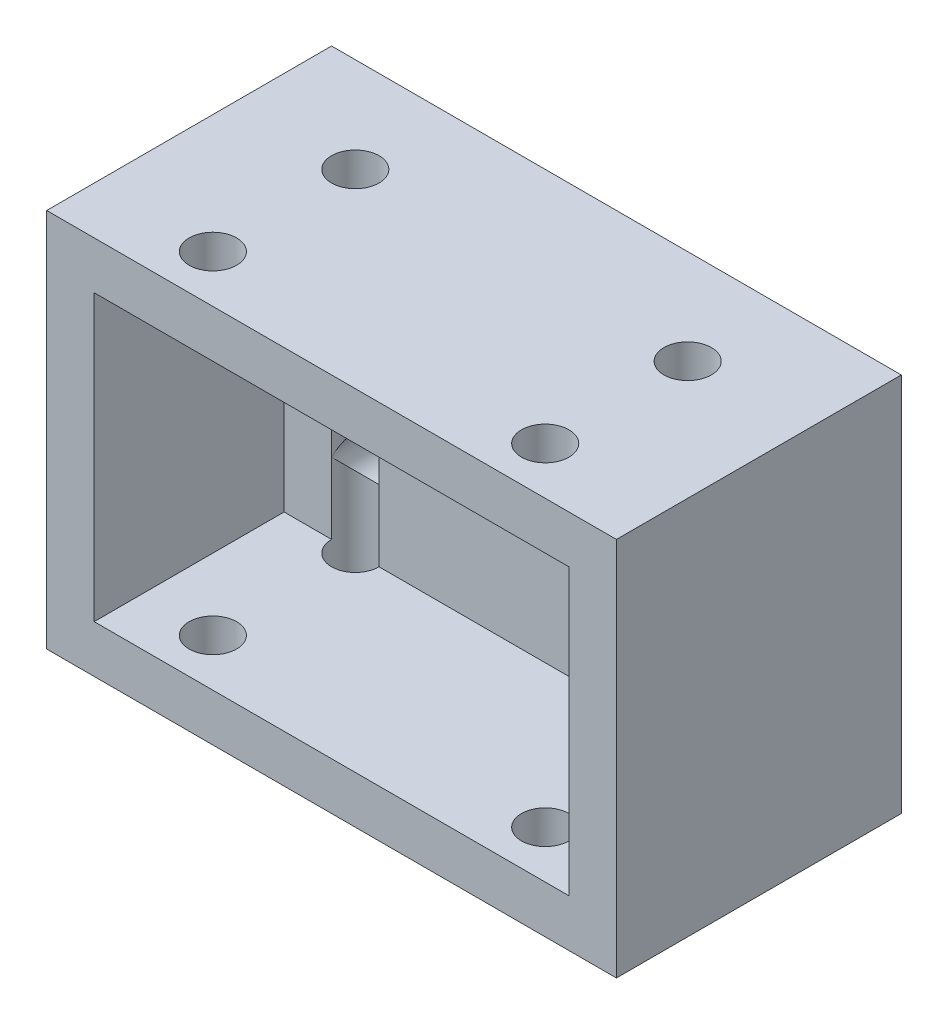
from build123d import *

# Parameters (mm, degrees)
SKETCH1_W           = 60
SKETCH1_H           = 40
SKETCH1_R           = 2.5
BOSS_EXTRUDE3_DEPTH = 30
SKETCH4_W           = 50
SKETCH4_H           = 30
CUT_EXTRUDE1_DEPTH  = 20
SKETCH5_R           = 2.5
CUT_EXTRUDE4_DEPTH  = 49


with BuildPart() as part:
    # Sketch1 → Boss-Extrude3 (new body)
    with BuildSketch(Plane.XY):
        Rectangle(SKETCH1_W, SKETCH1_H)
        with Locations((-17.5, 7.5)):
            Circle(SKETCH1_R, mode=Mode.SUBTRACT)
        with Locations((17.5, 7.5)):
            Circle(SKETCH1_R, mode=Mode.SUBTRACT)
        with Locations((-17.5, -7.5)):
            Circle(SKETCH1_R, mode=Mode.SUBTRACT)
        with Locations((17.5, -7.5)):
            Circle(SKETCH1_R, mode=Mode.SUBTRACT)
    extrude(amount=BOSS_EXTRUDE3_DEPTH)

    # Sketch4 → Cut-Extrude1 (cut)
    with BuildSketch(Plane.XY.offset(30)):
        Rectangle(SKETCH4_W, SKETCH4_H)
    extrude(amount=-CUT_EXTRUDE1_DEPTH, mode=Mode.SUBTRACT)

    # Sketch5 → Cut-Extrude4 (cut)
    with BuildSketch(Plane(origin=(0, 20, 0), x_dir=(1, 0, 0), z_dir=(0, 1, 0))):
        with Locations((-17.5, -10)):
            Circle(SKETCH5_R)
        with Locations((17.5, -10)):
            Circle(SKETCH5_R)
        with Locations((17.5, -25)):
            Circle(SKETCH5_R)
        with Locations((-17.5, -25)):
            Circle(SKETCH5_R)
    extrude(amount=-CUT_EXTRUDE4_DEPTH, mode=Mode.SUBTRACT)


solid = part.part
